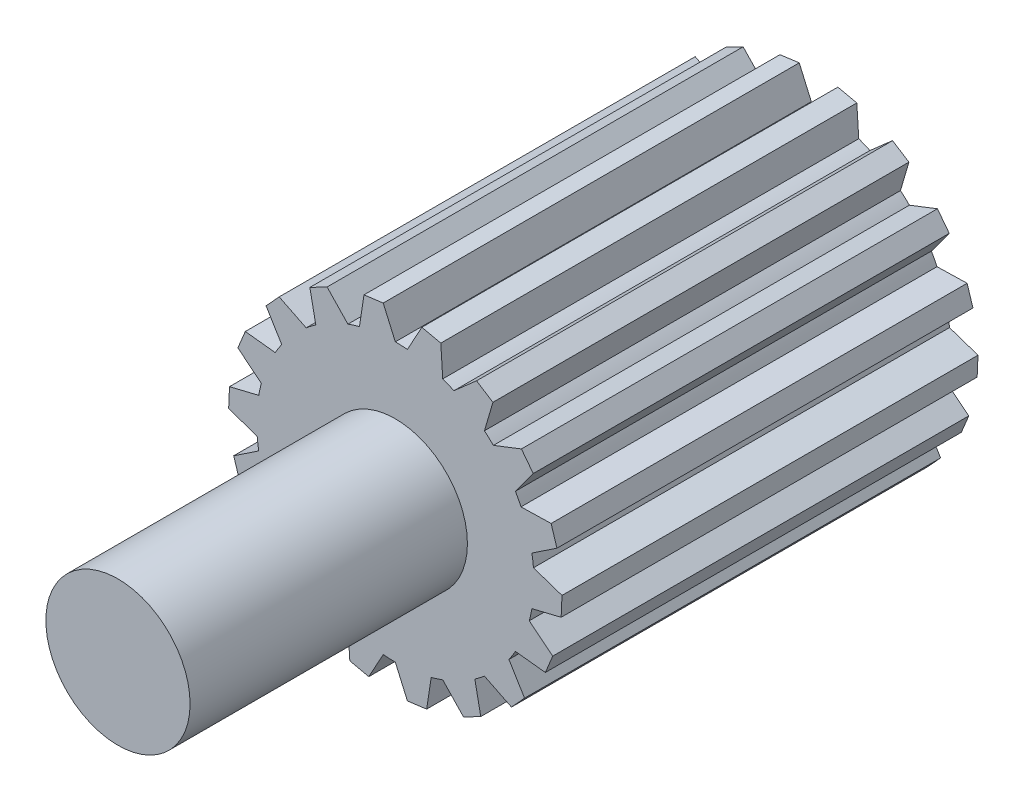
from build123d import *

# Parameters (mm, degrees)
SKETCH1_R           = 5
BOSS_EXTRUDE1_DEPTH = 15
SKETCH1_3_R         = 2.6
BOSS_EXTRUDE2_DEPTH = 25
BOSS_EXTRUDE3_DEPTH = 15


with BuildPart() as part:
    # Sketch1 → Boss-Extrude1 (new body)
    with BuildSketch(Plane.XY):
        Circle(SKETCH1_R)
    extrude(amount=BOSS_EXTRUDE1_DEPTH)

    # Sketch1_3 → Boss-Extrude2 (add)
    with BuildSketch(Plane.XY):
        Circle(SKETCH1_3_R)
    extrude(amount=BOSS_EXTRUDE2_DEPTH)

    # Sketch2 → Boss-Extrude3 (add)
    with BuildSketch(Plane(origin=(0, 0, 0), x_dir=(-1, 0, 0), z_dir=(0, 0, -1))):
        with BuildLine():
            Line((0.436151452, 5.994353336), (1.130162855, 5.902985001))
            Line((1.130162855, 5.902985001), (1.294095226, 4.829629131))
            ThreePointArc((1.294095226, 4.829629131), (0.652630961, 4.957224307), (0, 5))
            Line((0, 5), (0.436151452, 5.994353336))
        make_face()
        with BuildLine():
            Line((2.460037888, 5.483677014), (3.080945471, 5.160452984))
            Line((3.080945471, 5.160452984), (2.867882182, 4.095760221))
            ThreePointArc((2.867882182, 4.095760221), (2.308743066, 4.435054166), (1.710100717, 4.698463104))
            Line((1.710100717, 4.698463104), (2.460037888, 5.483677014))
        make_face()
        with BuildLine():
            Line((4.187207448, 4.311588314), (4.660120594, 3.795494178))
            Line((4.660120594, 3.795494178), (4.095760221, 2.867882182))
            ThreePointArc((4.095760221, 2.867882182), (3.686386684, 3.377951038), (3.213938048, 3.830222216))
            Line((3.213938048, 3.830222216), (4.187207448, 4.311588314))
        make_face()
        with BuildLine():
            Line((5.409337994, 2.619458431), (5.677216396, 1.972742758))
            Line((5.677216396, 1.972742758), (4.829629131, 1.294095226))
            ThreePointArc((4.829629131, 1.294095226), (4.619397663, 1.913417162), (4.330127019, 2.5))
            Line((4.330127019, 2.5), (5.409337994, 2.619458431))
        make_face()
        with BuildLine():
            Line((5.979022544, 0.611383202), (6.009556115, -0.087950553))
            Line((6.009556115, -0.087950553), (4.98097349, -0.435778714))
            ThreePointArc((4.98097349, -0.435778714), (4.995241108, 0.218096937), (4.924038765, 0.868240888))
            Line((4.924038765, 0.868240888), (5.979022544, 0.611383202))
        make_face()
        with BuildLine():
            Line((5.827548734, -1.470433864), (5.617054675, -2.13803573))
            Line((5.617054675, -2.13803573), (4.531538935, -2.113091309))
            ThreePointArc((4.531538935, -2.113091309), (4.768584754, -1.503528998), (4.924038765, -0.868240888))
            Line((4.924038765, -0.868240888), (5.827548734, -1.470433864))
        make_face()
        with BuildLine():
            Line((4.973186542, -3.374894905), (4.547053542, -3.930242243))
            Line((4.547053542, -3.930242243), (3.535533906, -3.535533906))
            ThreePointArc((3.535533906, -3.535533906), (3.966766701, -3.043807145), (4.330127019, -2.5))
            Line((4.330127019, -2.5), (4.973186542, -3.374894905))
        make_face()
        with BuildLine():
            Line((3.518984656, -4.872293812), (2.928610644, -5.248403538))
            Line((2.928610644, -5.248403538), (2.113091309, -4.531538935))
            ThreePointArc((2.113091309, -4.531538935), (2.686498042, -4.216957229), (3.213938048, -3.830222216))
            Line((3.213938048, -3.830222216), (3.518984656, -4.872293812))
        make_face()
        with BuildLine():
            Line((1.640341286, -5.782022178), (0.956934081, -5.933529908))
            Line((0.956934081, -5.933529908), (0.435778714, -4.98097349))
            ThreePointArc((0.435778714, -4.98097349), (1.08219807, -4.881480036), (1.710100717, -4.698463104))
            Line((1.710100717, -4.698463104), (1.640341286, -5.782022178))
        make_face()
        with BuildLine():
            Line((-0.436151452, -5.994353336), (-1.130162855, -5.902985001))
            Line((-1.130162855, -5.902985001), (-1.294095226, -4.829629131))
            ThreePointArc((-1.294095226, -4.829629131), (-0.652630961, -4.957224307), (0, -5))
            Line((0, -5), (-0.436151452, -5.994353336))
        make_face()
        with BuildLine():
            Line((-2.460037888, -5.483677014), (-3.080945471, -5.160452984))
            Line((-3.080945471, -5.160452984), (-2.867882182, -4.095760221))
            ThreePointArc((-2.867882182, -4.095760221), (-2.308743066, -4.435054166), (-1.710100717, -4.698463104))
            Line((-1.710100717, -4.698463104), (-2.460037888, -5.483677014))
        make_face()
        with BuildLine():
            Line((-4.187207448, -4.311588314), (-4.660120594, -3.795494178))
            Line((-4.660120594, -3.795494178), (-4.095760221, -2.867882182))
            ThreePointArc((-4.095760221, -2.867882182), (-3.686386684, -3.377951038), (-3.213938048, -3.830222216))
            Line((-3.213938048, -3.830222216), (-4.187207448, -4.311588314))
        make_face()
        with BuildLine():
            Line((-5.409337994, -2.619458431), (-5.677216396, -1.972742758))
            Line((-5.677216396, -1.972742758), (-4.829629131, -1.294095226))
            ThreePointArc((-4.829629131, -1.294095226), (-4.619397663, -1.913417162), (-4.330127019, -2.5))
            Line((-4.330127019, -2.5), (-5.409337994, -2.619458431))
        make_face()
        with BuildLine():
            Line((-5.979022544, -0.611383202), (-6.009556115, 0.087950553))
            Line((-6.009556115, 0.087950553), (-4.98097349, 0.435778714))
            ThreePointArc((-4.98097349, 0.435778714), (-4.995241108, -0.218096937), (-4.924038765, -0.868240888))
            Line((-4.924038765, -0.868240888), (-5.979022544, -0.611383202))
        make_face()
        with BuildLine():
            Line((-5.827548734, 1.470433864), (-5.617054675, 2.13803573))
            Line((-5.617054675, 2.13803573), (-4.531538935, 2.113091309))
            ThreePointArc((-4.531538935, 2.113091309), (-4.768584754, 1.503528998), (-4.924038765, 0.868240888))
            Line((-4.924038765, 0.868240888), (-5.827548734, 1.470433864))
        make_face()
        with BuildLine():
            Line((-4.973186542, 3.374894905), (-4.547053542, 3.930242243))
            Line((-4.547053542, 3.930242243), (-3.535533906, 3.535533906))
            ThreePointArc((-3.535533906, 3.535533906), (-3.966766701, 3.043807145), (-4.330127019, 2.5))
            Line((-4.330127019, 2.5), (-4.973186542, 3.374894905))
        make_face()
        with BuildLine():
            Line((-3.518984656, 4.872293812), (-2.928610644, 5.248403538))
            Line((-2.928610644, 5.248403538), (-2.113091309, 4.531538935))
            ThreePointArc((-2.113091309, 4.531538935), (-2.686498042, 4.216957229), (-3.213938048, 3.830222216))
            Line((-3.213938048, 3.830222216), (-3.518984656, 4.872293812))
        make_face()
        with BuildLine():
            Line((-1.640341286, 5.782022178), (-0.956934081, 5.933529908))
            Line((-0.956934081, 5.933529908), (-0.435778714, 4.98097349))
            ThreePointArc((-0.435778714, 4.98097349), (-1.08219807, 4.881480036), (-1.710100717, 4.698463104))
            Line((-1.710100717, 4.698463104), (-1.640341286, 5.782022178))
        make_face()
    extrude(amount=-BOSS_EXTRUDE3_DEPTH)


solid = part.part
